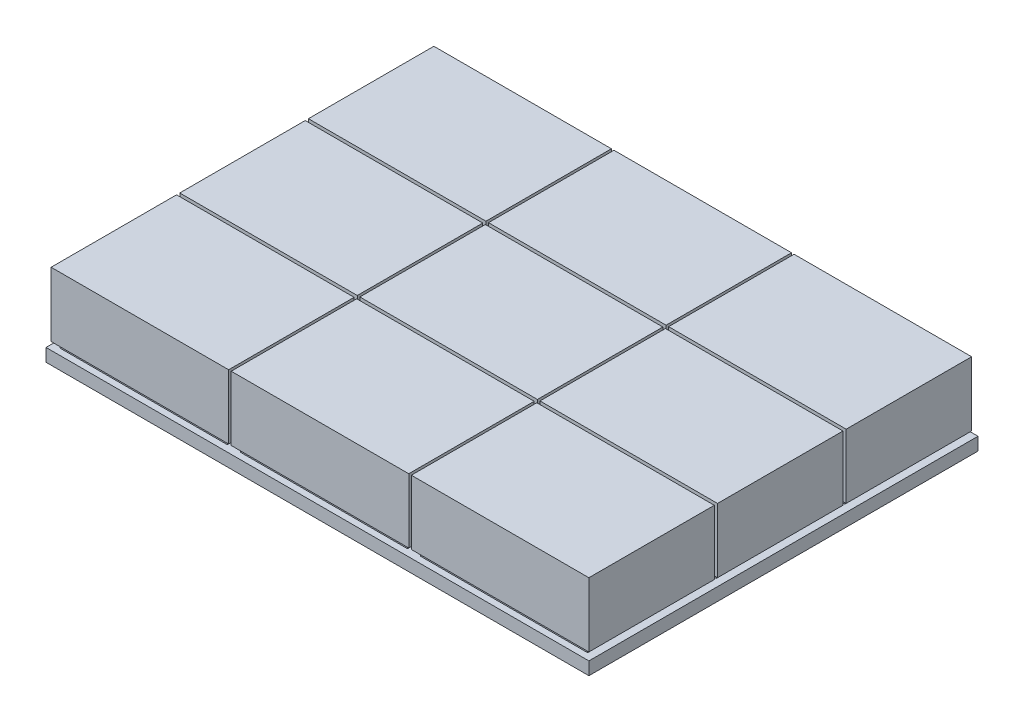
from build123d import *

# Parameters (mm, degrees)
SKETCH1_W                 = 71
SKETCH1_H                 = 250
BOSS_EXTRUDE1_DEPTH       = 5
SKETCH2_W                 = 65
SKETCH2_H                 = 45
BOSS_EXTRUDE3_DEPTH       = 2
LPATTERN1_COUNT           = 3
LPATTERN1_PITCH           = 50
SKETCH3_W                 = 69
SKETCH3_H                 = 48.754858224
BOSS_EXTRUDE8_DEPTH       = 25
LPATTERN5_COUNT           = 3
LPATTERN5_PITCH           = 50
LPATTERN6_COUNT           = 3
LPATTERN6_PITCH           = 70
LPATTERN6_COPY_1_SKETCH_W = 65
LPATTERN6_COPY_1_SKETCH_H = 45
LPATTERN6_COPY_1_DEPTH    = 2
LPATTERN6_COPY_2_SKETCH_W = 65
LPATTERN6_COPY_2_SKETCH_H = 45
LPATTERN6_COPY_2_DEPTH    = 2
LPATTERN6_COPY_3_SKETCH_W = 65
LPATTERN6_COPY_3_SKETCH_H = 45
LPATTERN6_COPY_3_DEPTH    = 2
LPATTERN6_COPY_4_SKETCH_W = 65
LPATTERN6_COPY_4_SKETCH_H = 45
LPATTERN6_COPY_4_DEPTH    = 2
LPATTERN6_COPY_5_SKETCH_W = 69
LPATTERN6_COPY_5_SKETCH_H = 48.754858224
LPATTERN6_COPY_5_DEPTH    = 25
LPATTERN6_COPY_6_SKETCH_W = 69
LPATTERN6_COPY_6_SKETCH_H = 48.754858224
LPATTERN6_COPY_6_DEPTH    = 25
LPATTERN6_COPY_7_SKETCH_W = 69
LPATTERN6_COPY_7_SKETCH_H = 48.754858224
LPATTERN6_COPY_7_DEPTH    = 25
LPATTERN6_COPY_8_SKETCH_W = 69
LPATTERN6_COPY_8_SKETCH_H = 48.754858224
LPATTERN6_COPY_8_DEPTH    = 25
SKETCH6_W                 = 211
SKETCH6_H                 = 98.778316014
CUT_EXTRUDE1_DEPTH        = 10


with BuildPart() as part:
    # Sketch1 → Boss-Extrude1 (new body)
    with BuildSketch(Plane(origin=(0, 0, 0), x_dir=(1, 0, 0), z_dir=(0, 1, 0))):
        Rectangle(SKETCH1_W, SKETCH1_H)
    boss_extrude1 = extrude(amount=BOSS_EXTRUDE1_DEPTH)

    # Sketch2 → Boss-Extrude3 (add)
    with BuildSketch(Plane(origin=(0, 5, 0), x_dir=(1, 0, 0), z_dir=(0, 1, 0))):
        with Locations((0, -100)):
            Rectangle(SKETCH2_W, SKETCH2_H)
    boss_extrude3 = extrude(amount=BOSS_EXTRUDE3_DEPTH)

    # LPattern1: Boss-Extrude3 ×3
    with Locations(*[(0, 0, -i * LPATTERN1_PITCH) for i in range(1, LPATTERN1_COUNT)]):
        add(boss_extrude3)

    # Sketch3 → Boss-Extrude8 (add)
    with BuildSketch(Plane(origin=(0, 7, 0), x_dir=(1, 0, 0), z_dir=(0, 1, 0))):
        with Locations((0, -99.635002086)):
            Rectangle(SKETCH3_W, SKETCH3_H)
    boss_extrude8 = extrude(amount=BOSS_EXTRUDE8_DEPTH)

    # LPattern5: Boss-Extrude8 ×3
    with Locations(*[(0, 0, -i * LPATTERN5_PITCH) for i in range(1, LPATTERN5_COUNT)]):
        add(boss_extrude8)

    # LPattern6: Boss-Extrude1, Boss-Extrude3, Boss-Extrude8 ×3
    with Locations(*[(i * LPATTERN6_PITCH, 0, 0) for i in range(1, LPATTERN6_COUNT)]):
        add(boss_extrude1)
        add(boss_extrude3)
        add(boss_extrude8)

    # LPattern6 copy 1 sketch → LPattern6 copy 1 (add)
    with BuildSketch(Plane(origin=(70, 5, -50), x_dir=(1, 0, 0), z_dir=(0, 1, 0))):
        with Locations((0, -100)):
            Rectangle(LPATTERN6_COPY_1_SKETCH_W, LPATTERN6_COPY_1_SKETCH_H)
    extrude(amount=LPATTERN6_COPY_1_DEPTH)

    # LPattern6 copy 2 sketch → LPattern6 copy 2 (add)
    with BuildSketch(Plane(origin=(140, 5, -50), x_dir=(1, 0, 0), z_dir=(0, 1, 0))):
        with Locations((0, -100)):
            Rectangle(LPATTERN6_COPY_2_SKETCH_W, LPATTERN6_COPY_2_SKETCH_H)
    extrude(amount=LPATTERN6_COPY_2_DEPTH)

    # LPattern6 copy 3 sketch → LPattern6 copy 3 (add)
    with BuildSketch(Plane(origin=(70, 5, -100), x_dir=(1, 0, 0), z_dir=(0, 1, 0))):
        with Locations((0, -100)):
            Rectangle(LPATTERN6_COPY_3_SKETCH_W, LPATTERN6_COPY_3_SKETCH_H)
    extrude(amount=LPATTERN6_COPY_3_DEPTH)

    # LPattern6 copy 4 sketch → LPattern6 copy 4 (add)
    with BuildSketch(Plane(origin=(140, 5, -100), x_dir=(1, 0, 0), z_dir=(0, 1, 0))):
        with Locations((0, -100)):
            Rectangle(LPATTERN6_COPY_4_SKETCH_W, LPATTERN6_COPY_4_SKETCH_H)
    extrude(amount=LPATTERN6_COPY_4_DEPTH)

    # LPattern6 copy 5 sketch → LPattern6 copy 5 (add)
    with BuildSketch(Plane(origin=(70, 7, -50), x_dir=(1, 0, 0), z_dir=(0, 1, 0))):
        with Locations((0, -99.635002086)):
            Rectangle(LPATTERN6_COPY_5_SKETCH_W, LPATTERN6_COPY_5_SKETCH_H)
    extrude(amount=LPATTERN6_COPY_5_DEPTH)

    # LPattern6 copy 6 sketch → LPattern6 copy 6 (add)
    with BuildSketch(Plane(origin=(140, 7, -50), x_dir=(1, 0, 0), z_dir=(0, 1, 0))):
        with Locations((0, -99.635002086)):
            Rectangle(LPATTERN6_COPY_6_SKETCH_W, LPATTERN6_COPY_6_SKETCH_H)
    extrude(amount=LPATTERN6_COPY_6_DEPTH)

    # LPattern6 copy 7 sketch → LPattern6 copy 7 (add)
    with BuildSketch(Plane(origin=(70, 7, -100), x_dir=(1, 0, 0), z_dir=(0, 1, 0))):
        with Locations((0, -99.635002086)):
            Rectangle(LPATTERN6_COPY_7_SKETCH_W, LPATTERN6_COPY_7_SKETCH_H)
    extrude(amount=LPATTERN6_COPY_7_DEPTH)

    # LPattern6 copy 8 sketch → LPattern6 copy 8 (add)
    with BuildSketch(Plane(origin=(140, 7, -100), x_dir=(1, 0, 0), z_dir=(0, 1, 0))):
        with Locations((0, -99.635002086)):
            Rectangle(LPATTERN6_COPY_8_SKETCH_W, LPATTERN6_COPY_8_SKETCH_H)
    extrude(amount=LPATTERN6_COPY_8_DEPTH)

    # Sketch6 → Cut-Extrude1 (cut)
    with BuildSketch(Plane(origin=(0, 5, 0), x_dir=(1, 0, 0), z_dir=(0, 1, 0))):
        with Locations((70, 75.610841993)):
            Rectangle(SKETCH6_W, SKETCH6_H)
    extrude(amount=-CUT_EXTRUDE1_DEPTH, mode=Mode.SUBTRACT)


solid = part.part
